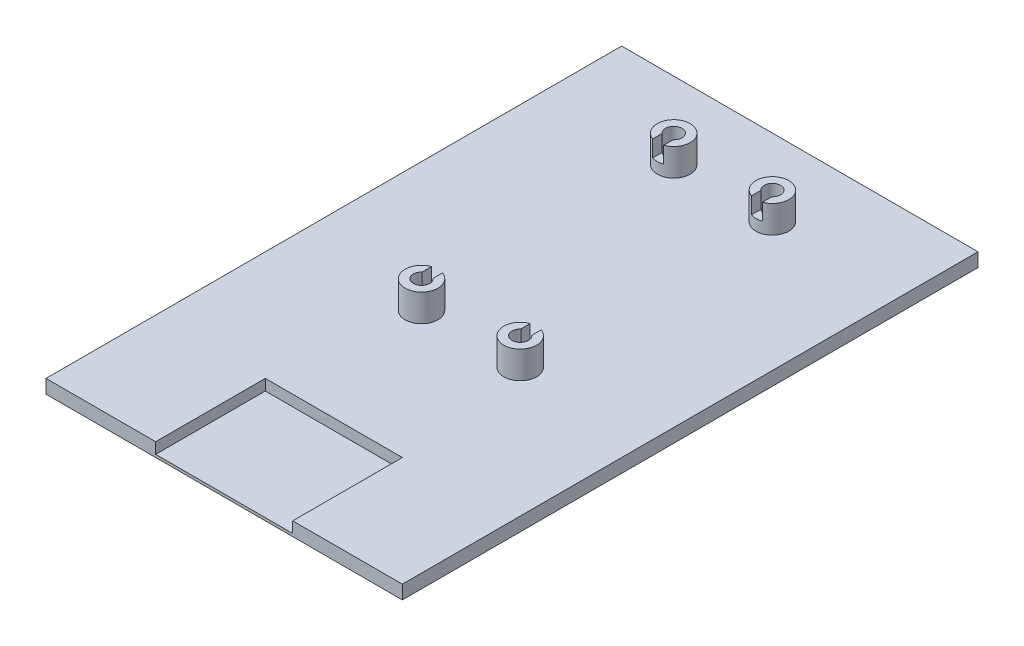
from build123d import *

# Parameters (mm, degrees)
SKETCH1_W           = 61
SKETCH1_H           = 101
BOSS_EXTRUDE1_DEPTH = 2
SKETCH2_W           = 65
SKETCH2_H           = 105
BOSS_EXTRUDE2_DEPTH = 2.5
SKETCH4_R           = 3
SKETCH4_R_2         = 1.5
BOSS_EXTRUDE3_DEPTH = 5
SKETCH5_W           = 25
SKETCH5_H           = 32
CUT_EXTRUDE1_DEPTH  = 2
SKETCH6_W           = 2
SKETCH6_H           = 4
CUT_EXTRUDE2_DEPTH  = 3
CUT_EXTRUDE3_DEPTH  = 2.5


with BuildPart() as part:
    # Sketch1 → Boss-Extrude1 (new body)
    with BuildSketch(Plane(origin=(0, 0, 0), x_dir=(1, 0, 0), z_dir=(0, 1, 0))):
        Rectangle(SKETCH1_W, SKETCH1_H)
    extrude(amount=BOSS_EXTRUDE1_DEPTH)

    # Sketch2 → Boss-Extrude2 (add)
    with BuildSketch(Plane(origin=(0, 2, 0), x_dir=(1, 0, 0), z_dir=(0, 1, 0))):
        Rectangle(SKETCH2_W, SKETCH2_H)
    extrude(amount=BOSS_EXTRUDE2_DEPTH)

    # Sketch4 → Boss-Extrude3 (add)
    with BuildSketch(Plane(origin=(0, 4.5, 0), x_dir=(1, 0, 0), z_dir=(0, 1, 0))):
        with Locations((-9, -7.5)):
            Circle(SKETCH4_R)
        with Locations((-9, -7.5)):
            Circle(SKETCH4_R_2, mode=Mode.SUBTRACT)
        with Locations((9, -7.5)):
            Circle(SKETCH4_R)
        with Locations((9, -7.5)):
            Circle(SKETCH4_R_2, mode=Mode.SUBTRACT)
        with Locations((9, 38.5)):
            Circle(SKETCH4_R)
        with Locations((9, 38.5)):
            Circle(SKETCH4_R_2, mode=Mode.SUBTRACT)
        with Locations((-9, 38.5)):
            Circle(SKETCH4_R)
        with Locations((-9, 38.5)):
            Circle(SKETCH4_R_2, mode=Mode.SUBTRACT)
    extrude(amount=BOSS_EXTRUDE3_DEPTH)

    # Sketch5 → Cut-Extrude1 (cut)
    with BuildSketch(Plane(origin=(0, 4.5, 0), x_dir=(1, 0, 0), z_dir=(0, 1, 0))):
        with Locations((0, -48.5)):
            Rectangle(SKETCH5_W, SKETCH5_H)
    extrude(amount=-CUT_EXTRUDE1_DEPTH, mode=Mode.SUBTRACT)

    # Sketch6 → Cut-Extrude2 (cut)
    with BuildSketch(Plane(origin=(0, 9.5, 0), x_dir=(1, 0, 0), z_dir=(0, 1, 0))):
        with Locations((9, -6)):
            Rectangle(SKETCH6_W, SKETCH6_H)
        with Locations((-9, -6)):
            Rectangle(SKETCH6_W, SKETCH6_H)
        with Locations((9, 37)):
            Rectangle(SKETCH6_W, SKETCH6_H)
        with Locations((-9, 37)):
            Rectangle(SKETCH6_W, SKETCH6_H)
    extrude(amount=-CUT_EXTRUDE2_DEPTH, mode=Mode.SUBTRACT)

    # Sketch7 → Cut-Extrude3 (cut)
    with BuildSketch(Plane.XZ):
        Polygon((-16.5, 28.5), (16.5, 28.5), (16.5, 46.5), (26.5, 46.5), (26.5, 28.5), (26.5, -46.5), (-26.5, -46.5), (-26.5, 28.5), (-26.5, 46.5), (-16.5, 46.5), align=None)
    extrude(amount=-CUT_EXTRUDE3_DEPTH, mode=Mode.SUBTRACT)


solid = part.part
